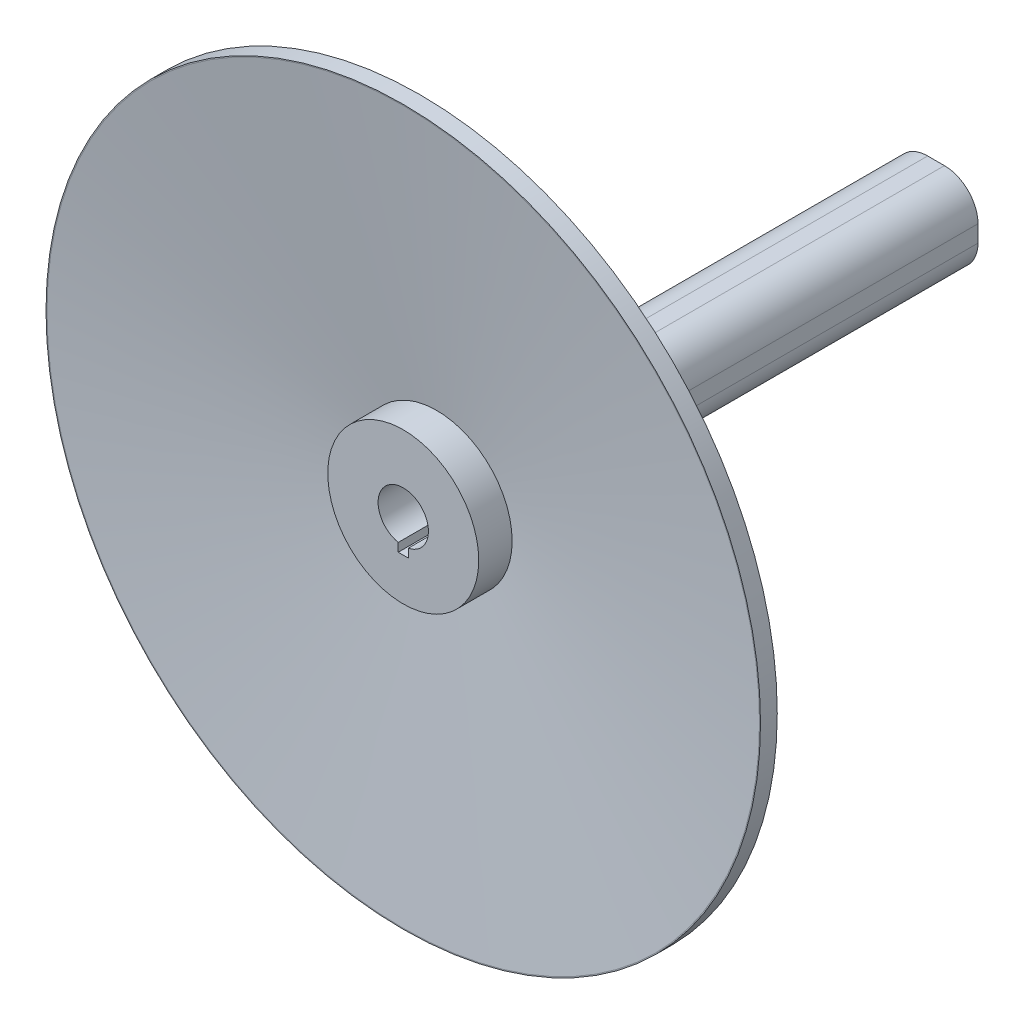
from build123d import *

# Parameters (mm, degrees)
SKETCH1_R           = 22.5
BOSS_EXTRUDE1_DEPTH = 60
BOSS_EXTRUDE2_DEPTH = 98.836337037
SKETCH6_R           = 7.5
CUT_EXTRUDE1_DEPTH  = 159.836337037
CUT_EXTRUDE2_DEPTH  = 50


with BuildPart() as part:
    # Sketch1 → Boss-Extrude1 (new body)
    with BuildSketch(Plane.XY):
        Circle(SKETCH1_R)
    extrude(amount=BOSS_EXTRUDE1_DEPTH)

    # Sketch4 → Boss-Extrude2 (add)
    with BuildSketch(Plane(origin=(0, 0, 0), x_dir=(-1, 0, 0), z_dir=(0, 0, -1))):
        with BuildLine():
            Line((-2.5, 12.5), (2.5, 12.5))
            ThreePointArc((2.5, 12.5), (9.571067812, 9.571067812), (12.5, 2.5))
            Line((12.5, 2.5), (12.5, -2.5))
            ThreePointArc((12.5, -2.5), (9.571067812, -9.571067812), (2.5, -12.5))
            Line((2.5, -12.5), (-2.5, -12.5))
            ThreePointArc((-2.5, -12.5), (-9.571067812, -9.571067812), (-12.5, -2.5))
            Line((-12.5, -2.5), (-12.5, 2.5))
            ThreePointArc((-12.5, 2.5), (-9.571067812, 9.571067812), (-2.5, 12.5))
        make_face()
    extrude(amount=BOSS_EXTRUDE2_DEPTH)

    # Sketch5 → Revolve1 (revolve)
    with BuildSketch(Plane(origin=(0, 0, 0), x_dir=(0, 0, -1), z_dir=(1, 0, 0))):
        Polygon((-60, 106.5), (-60, 106.203428035), (-50.035306186, 22.5), (-45, 22.5), (-55, 106.5), align=None)
    revolve(axis=Axis((0, 0, 60), (0, 0, -1)))

    # Sketch6 → Cut-Extrude1 (cut, through all)
    with BuildSketch(Plane(origin=(0, 0, -98.836337037), x_dir=(-1, 0, 0), z_dir=(0, 0, -1))):
        Circle(SKETCH6_R)
    extrude(amount=-CUT_EXTRUDE1_DEPTH, mode=Mode.SUBTRACT)

    # Sketch7 → Cut-Extrude2 (cut)
    with BuildSketch(Plane.XY.offset(60)):
        with BuildLine():
            ThreePointArc((1.5, -7.348469228), (0, -7.5), (-1.5, -7.348469228))
            Line((-1.5, -7.348469228), (-1.5, -9.886859967))
            Line((-1.5, -9.886859967), (1.5, -9.886859967))
            Line((1.5, -9.886859967), (1.5, -7.348469228))
        make_face()
    extrude(amount=-CUT_EXTRUDE2_DEPTH, mode=Mode.SUBTRACT)


solid = part.part
